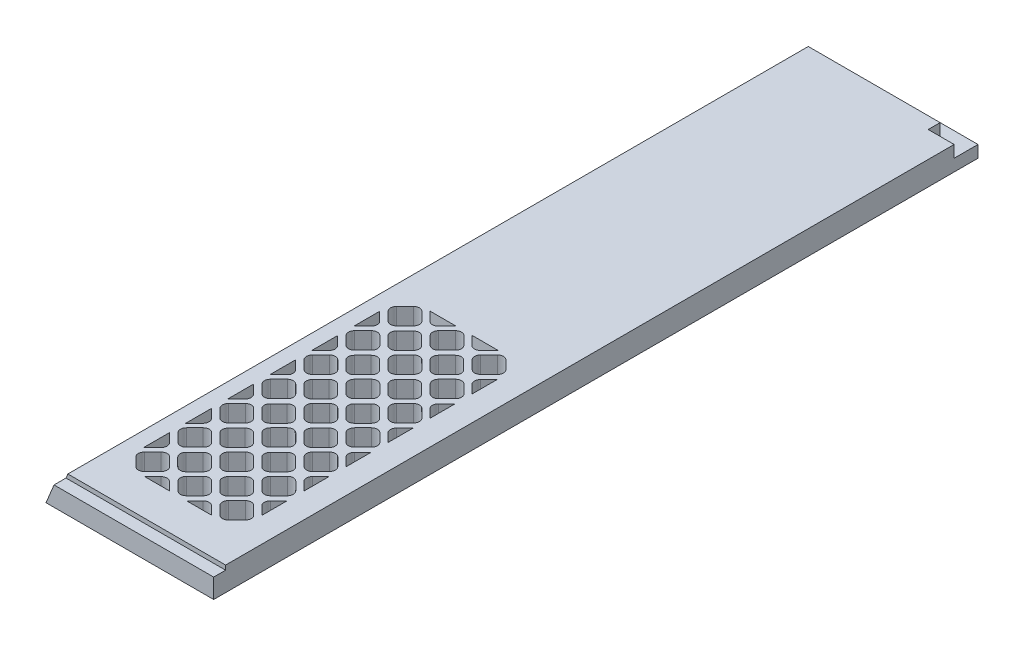
from build123d import *

# Parameters (mm, degrees)
BOSS_EXTRUDE1_DEPTH = 406.4
SKETCH2_W           = 89.154
SKETCH2_H           = 6.35
CUT_EXTRUDE1_DEPTH  = 2.3622
CUT_EXTRUDE2_DEPTH  = 13.7
CUT_EXTRUDE3_DEPTH  = 6.35


with BuildPart() as part:
    # Sketch1 → Boss-Extrude1 (new body)
    with BuildSketch(Plane.XY):
        Polygon((0, 0), (5.260512242, 12.7), (89.154, 12.7), (89.154, 0), align=None)
    extrude(amount=BOSS_EXTRUDE1_DEPTH)

    # Sketch2 → Cut-Extrude1 (cut)
    with BuildSketch(Plane.XZ.offset(-12.7)):
        with Locations((44.577, 403.225)):
            Rectangle(SKETCH2_W, SKETCH2_H)
    extrude(amount=CUT_EXTRUDE1_DEPTH, mode=Mode.SUBTRACT)

    # Sketch3 → Cut-Extrude2 (cut, through all)
    with BuildSketch(Plane.XZ):
        with BuildLine():
            ThreePointArc((28.960192091, 374.10106403), (29.890128061, 371.856), (28.960192091, 369.61093597))
            Line((28.960192091, 369.61093597), (24.47006403, 365.120807909))
            ThreePointArc((24.47006403, 365.120807909), (22.225, 364.190871939), (19.97993597, 365.120807909))
            Line((19.97993597, 365.120807909), (15.489807909, 369.61093597))
            ThreePointArc((15.489807909, 369.61093597), (14.559871939, 371.856), (15.489807909, 374.10106403))
            Line((15.489807909, 374.10106403), (19.97993597, 378.591192091))
            ThreePointArc((19.97993597, 378.591192091), (22.225, 379.521128061), (24.47006403, 378.591192091))
            Line((24.47006403, 378.591192091), (28.960192091, 374.10106403))
        make_face()
        with BuildLine():
            Line((37.841807909, 374.10106403), (42.33193597, 378.591192091))
            ThreePointArc((42.33193597, 378.591192091), (44.577, 379.521128061), (46.82206403, 378.591192091))
            Line((46.82206403, 378.591192091), (51.312192091, 374.10106403))
            ThreePointArc((51.312192091, 374.10106403), (52.242128061, 371.856), (51.312192091, 369.61093597))
            Line((51.312192091, 369.61093597), (46.82206403, 365.120807909))
            ThreePointArc((46.82206403, 365.120807909), (44.577, 364.190871939), (42.33193597, 365.120807909))
            Line((42.33193597, 365.120807909), (37.841807909, 369.61093597))
            ThreePointArc((37.841807909, 369.61093597), (36.911871939, 371.856), (37.841807909, 374.10106403))
        make_face()
        with BuildLine():
            Line((60.193807909, 374.10106403), (64.68393597, 378.591192091))
            ThreePointArc((64.68393597, 378.591192091), (66.929, 379.521128061), (69.17406403, 378.591192091))
            Line((69.17406403, 378.591192091), (73.664192091, 374.10106403))
            ThreePointArc((73.664192091, 374.10106403), (74.594128061, 371.856), (73.664192091, 369.61093597))
            Line((73.664192091, 369.61093597), (69.17406403, 365.120807909))
            ThreePointArc((69.17406403, 365.120807909), (66.929, 364.190871939), (64.68393597, 365.120807909))
            Line((64.68393597, 365.120807909), (60.193807909, 369.61093597))
            ThreePointArc((60.193807909, 369.61093597), (59.263871939, 371.856), (60.193807909, 374.10106403))
        make_face()
        with BuildLine():
            ThreePointArc((53.598045847, 367.603942271), (55.843109877, 368.533878241), (58.088173908, 367.603942271))
            Line((58.088173908, 367.603942271), (62.578301968, 363.113814211))
            ThreePointArc((62.578301968, 363.113814211), (63.508237938, 360.86875018), (62.578301968, 358.62368615))
            Line((62.578301968, 358.62368615), (58.088173908, 354.13355809))
            ThreePointArc((58.088173908, 354.13355809), (55.843109877, 353.20362212), (53.598045847, 354.13355809))
            Line((53.598045847, 354.13355809), (49.107917787, 358.62368615))
            ThreePointArc((49.107917787, 358.62368615), (48.177981817, 360.86875018), (49.107917787, 363.113814211))
            Line((49.107917787, 363.113814211), (53.598045847, 367.603942271))
        make_face()
        with BuildLine():
            ThreePointArc((31.246045847, 367.603942271), (33.491109877, 368.533878241), (35.736173908, 367.603942271))
            Line((35.736173908, 367.603942271), (40.226301968, 363.113814211))
            ThreePointArc((40.226301968, 363.113814211), (41.156237938, 360.86875018), (40.226301968, 358.62368615))
            Line((40.226301968, 358.62368615), (35.736173908, 354.13355809))
            ThreePointArc((35.736173908, 354.13355809), (33.491109877, 353.20362212), (31.246045847, 354.13355809))
            Line((31.246045847, 354.13355809), (26.755917787, 358.62368615))
            ThreePointArc((26.755917787, 358.62368615), (25.825981817, 360.86875018), (26.755917787, 363.113814211))
            Line((26.755917787, 363.113814211), (31.246045847, 367.603942271))
        make_face()
        with BuildLine():
            Line((15.489807909, 351.74906403), (19.97993597, 356.239192091))
            ThreePointArc((19.97993597, 356.239192091), (22.225, 357.169128061), (24.47006403, 356.239192091))
            Line((24.47006403, 356.239192091), (28.960192091, 351.74906403))
            ThreePointArc((28.960192091, 351.74906403), (29.890128061, 349.504), (28.960192091, 347.25893597))
            Line((28.960192091, 347.25893597), (24.47006403, 342.768807909))
            ThreePointArc((24.47006403, 342.768807909), (22.225, 341.838871939), (19.97993597, 342.768807909))
            Line((19.97993597, 342.768807909), (15.489807909, 347.25893597))
            ThreePointArc((15.489807909, 347.25893597), (14.559871939, 349.504), (15.489807909, 351.74906403))
        make_face()
        with BuildLine():
            Line((37.841807909, 351.74906403), (42.33193597, 356.239192091))
            ThreePointArc((42.33193597, 356.239192091), (44.577, 357.169128061), (46.82206403, 356.239192091))
            Line((46.82206403, 356.239192091), (51.312192091, 351.74906403))
            ThreePointArc((51.312192091, 351.74906403), (52.242128061, 349.504), (51.312192091, 347.25893597))
            Line((51.312192091, 347.25893597), (46.82206403, 342.768807909))
            ThreePointArc((46.82206403, 342.768807909), (44.577, 341.838871939), (42.33193597, 342.768807909))
            Line((42.33193597, 342.768807909), (37.841807909, 347.25893597))
            ThreePointArc((37.841807909, 347.25893597), (36.911871939, 349.504), (37.841807909, 351.74906403))
        make_face()
        with BuildLine():
            Line((60.193807909, 351.74906403), (64.68393597, 356.239192091))
            ThreePointArc((64.68393597, 356.239192091), (66.929, 357.169128061), (69.17406403, 356.239192091))
            Line((69.17406403, 356.239192091), (73.664192091, 351.74906403))
            ThreePointArc((73.664192091, 351.74906403), (74.594128061, 349.504), (73.664192091, 347.25893597))
            Line((73.664192091, 347.25893597), (69.17406403, 342.768807909))
            ThreePointArc((69.17406403, 342.768807909), (66.929, 341.838871939), (64.68393597, 342.768807909))
            Line((64.68393597, 342.768807909), (60.193807909, 347.25893597))
            ThreePointArc((60.193807909, 347.25893597), (59.263871939, 349.504), (60.193807909, 351.74906403))
        make_face()
        with BuildLine():
            ThreePointArc((53.598045847, 345.251942271), (55.843109877, 346.181878241), (58.088173908, 345.251942271))
            Line((58.088173908, 345.251942271), (62.578301968, 340.761814211))
            ThreePointArc((62.578301968, 340.761814211), (63.508237938, 338.51675018), (62.578301968, 336.27168615))
            Line((62.578301968, 336.27168615), (58.088173908, 331.78155809))
            ThreePointArc((58.088173908, 331.78155809), (55.843109877, 330.85162212), (53.598045847, 331.78155809))
            Line((53.598045847, 331.78155809), (49.107917787, 336.27168615))
            ThreePointArc((49.107917787, 336.27168615), (48.177981817, 338.51675018), (49.107917787, 340.761814211))
            Line((49.107917787, 340.761814211), (53.598045847, 345.251942271))
        make_face()
        with BuildLine():
            ThreePointArc((31.246045847, 345.251942271), (33.491109877, 346.181878241), (35.736173908, 345.251942271))
            Line((35.736173908, 345.251942271), (40.226301968, 340.761814211))
            ThreePointArc((40.226301968, 340.761814211), (41.156237938, 338.51675018), (40.226301968, 336.27168615))
            Line((40.226301968, 336.27168615), (35.736173908, 331.78155809))
            ThreePointArc((35.736173908, 331.78155809), (33.491109877, 330.85162212), (31.246045847, 331.78155809))
            Line((31.246045847, 331.78155809), (26.755917787, 336.27168615))
            ThreePointArc((26.755917787, 336.27168615), (25.825981817, 338.51675018), (26.755917787, 340.761814211))
            Line((26.755917787, 340.761814211), (31.246045847, 345.251942271))
        make_face()
        with BuildLine():
            Line((15.489807909, 329.39706403), (19.97993597, 333.887192091))
            ThreePointArc((19.97993597, 333.887192091), (22.225, 334.817128061), (24.47006403, 333.887192091))
            Line((24.47006403, 333.887192091), (28.960192091, 329.39706403))
            ThreePointArc((28.960192091, 329.39706403), (29.890128061, 327.152), (28.960192091, 324.90693597))
            Line((28.960192091, 324.90693597), (24.47006403, 320.416807909))
            ThreePointArc((24.47006403, 320.416807909), (22.225, 319.486871939), (19.97993597, 320.416807909))
            Line((19.97993597, 320.416807909), (15.489807909, 324.90693597))
            ThreePointArc((15.489807909, 324.90693597), (14.559871939, 327.152), (15.489807909, 329.39706403))
        make_face()
        with BuildLine():
            Line((37.841807909, 329.39706403), (42.33193597, 333.887192091))
            ThreePointArc((42.33193597, 333.887192091), (44.577, 334.817128061), (46.82206403, 333.887192091))
            Line((46.82206403, 333.887192091), (51.312192091, 329.39706403))
            ThreePointArc((51.312192091, 329.39706403), (52.242128061, 327.152), (51.312192091, 324.90693597))
            Line((51.312192091, 324.90693597), (46.82206403, 320.416807909))
            ThreePointArc((46.82206403, 320.416807909), (44.577, 319.486871939), (42.33193597, 320.416807909))
            Line((42.33193597, 320.416807909), (37.841807909, 324.90693597))
            ThreePointArc((37.841807909, 324.90693597), (36.911871939, 327.152), (37.841807909, 329.39706403))
        make_face()
        with BuildLine():
            Line((60.193807909, 329.39706403), (64.68393597, 333.887192091))
            ThreePointArc((64.68393597, 333.887192091), (66.929, 334.817128061), (69.17406403, 333.887192091))
            Line((69.17406403, 333.887192091), (73.664192091, 329.39706403))
            ThreePointArc((73.664192091, 329.39706403), (74.594128061, 327.152), (73.664192091, 324.90693597))
            Line((73.664192091, 324.90693597), (69.17406403, 320.416807909))
            ThreePointArc((69.17406403, 320.416807909), (66.929, 319.486871939), (64.68393597, 320.416807909))
            Line((64.68393597, 320.416807909), (60.193807909, 324.90693597))
            ThreePointArc((60.193807909, 324.90693597), (59.263871939, 327.152), (60.193807909, 329.39706403))
        make_face()
        with BuildLine():
            ThreePointArc((31.246045847, 322.899942271), (33.491109877, 323.829878241), (35.736173908, 322.899942271))
            Line((35.736173908, 322.899942271), (40.226301968, 318.409814211))
            ThreePointArc((40.226301968, 318.409814211), (41.156237938, 316.164750181), (40.226301968, 313.91968615))
            Line((40.226301968, 313.91968615), (35.736173908, 309.42955809))
            ThreePointArc((35.736173908, 309.42955809), (33.491109877, 308.49962212), (31.246045847, 309.42955809))
            Line((31.246045847, 309.42955809), (26.755917787, 313.91968615))
            ThreePointArc((26.755917787, 313.91968615), (25.825981817, 316.164750181), (26.755917787, 318.409814211))
            Line((26.755917787, 318.409814211), (31.246045847, 322.899942271))
        make_face()
        with BuildLine():
            ThreePointArc((53.598045847, 322.899942271), (55.843109877, 323.829878241), (58.088173908, 322.899942271))
            Line((58.088173908, 322.899942271), (62.578301968, 318.409814211))
            ThreePointArc((62.578301968, 318.409814211), (63.508237938, 316.164750181), (62.578301968, 313.91968615))
            Line((62.578301968, 313.91968615), (58.088173908, 309.42955809))
            ThreePointArc((58.088173908, 309.42955809), (55.843109877, 308.49962212), (53.598045847, 309.42955809))
            Line((53.598045847, 309.42955809), (49.107917787, 313.91968615))
            ThreePointArc((49.107917787, 313.91968615), (48.177981817, 316.164750181), (49.107917787, 318.409814211))
            Line((49.107917787, 318.409814211), (53.598045847, 322.899942271))
        make_face()
        with BuildLine():
            Line((15.489807909, 307.04506403), (19.97993597, 311.535192091))
            ThreePointArc((19.97993597, 311.535192091), (22.225, 312.465128061), (24.47006403, 311.535192091))
            Line((24.47006403, 311.535192091), (28.960192091, 307.04506403))
            ThreePointArc((28.960192091, 307.04506403), (29.890128061, 304.8), (28.960192091, 302.55493597))
            Line((28.960192091, 302.55493597), (24.47006403, 298.064807909))
            ThreePointArc((24.47006403, 298.064807909), (22.225, 297.134871939), (19.97993597, 298.064807909))
            Line((19.97993597, 298.064807909), (15.489807909, 302.55493597))
            ThreePointArc((15.489807909, 302.55493597), (14.559871939, 304.8), (15.489807909, 307.04506403))
        make_face()
        with BuildLine():
            Line((37.841807909, 307.04506403), (42.33193597, 311.535192091))
            ThreePointArc((42.33193597, 311.535192091), (44.577, 312.465128061), (46.82206403, 311.535192091))
            Line((46.82206403, 311.535192091), (51.312192091, 307.04506403))
            ThreePointArc((51.312192091, 307.04506403), (52.242128061, 304.8), (51.312192091, 302.55493597))
            Line((51.312192091, 302.55493597), (46.82206403, 298.064807909))
            ThreePointArc((46.82206403, 298.064807909), (44.577, 297.134871939), (42.33193597, 298.064807909))
            Line((42.33193597, 298.064807909), (37.841807909, 302.55493597))
            ThreePointArc((37.841807909, 302.55493597), (36.911871939, 304.8), (37.841807909, 307.04506403))
        make_face()
        with BuildLine():
            Line((60.193807909, 307.04506403), (64.68393597, 311.535192091))
            ThreePointArc((64.68393597, 311.535192091), (66.929, 312.465128061), (69.17406403, 311.535192091))
            Line((69.17406403, 311.535192091), (73.664192091, 307.04506403))
            ThreePointArc((73.664192091, 307.04506403), (74.594128061, 304.8), (73.664192091, 302.55493597))
            Line((73.664192091, 302.55493597), (69.17406403, 298.064807909))
            ThreePointArc((69.17406403, 298.064807909), (66.929, 297.134871939), (64.68393597, 298.064807909))
            Line((64.68393597, 298.064807909), (60.193807909, 302.55493597))
            ThreePointArc((60.193807909, 302.55493597), (59.263871939, 304.8), (60.193807909, 307.04506403))
        make_face()
        with BuildLine():
            ThreePointArc((53.598045847, 300.547942271), (55.843109877, 301.477878241), (58.088173908, 300.547942271))
            Line((58.088173908, 300.547942271), (62.578301968, 296.057814211))
            ThreePointArc((62.578301968, 296.057814211), (63.508237938, 293.812750181), (62.578301968, 291.56768615))
            Line((62.578301968, 291.56768615), (58.088173908, 287.07755809))
            ThreePointArc((58.088173908, 287.07755809), (55.843109877, 286.14762212), (53.598045847, 287.07755809))
            Line((53.598045847, 287.07755809), (49.107917787, 291.56768615))
            ThreePointArc((49.107917787, 291.56768615), (48.177981817, 293.812750181), (49.107917787, 296.057814211))
            Line((49.107917787, 296.057814211), (53.598045847, 300.547942271))
        make_face()
        with BuildLine():
            ThreePointArc((31.246045847, 300.547942271), (33.491109877, 301.477878241), (35.736173908, 300.547942271))
            Line((35.736173908, 300.547942271), (40.226301968, 296.057814211))
            ThreePointArc((40.226301968, 296.057814211), (41.156237938, 293.812750181), (40.226301968, 291.56768615))
            Line((40.226301968, 291.56768615), (35.736173908, 287.07755809))
            ThreePointArc((35.736173908, 287.07755809), (33.491109877, 286.14762212), (31.246045847, 287.07755809))
            Line((31.246045847, 287.07755809), (26.755917787, 291.56768615))
            ThreePointArc((26.755917787, 291.56768615), (25.825981817, 293.812750181), (26.755917787, 296.057814211))
            Line((26.755917787, 296.057814211), (31.246045847, 300.547942271))
        make_face()
        with BuildLine():
            Line((15.489807909, 284.69306403), (19.97993597, 289.183192091))
            ThreePointArc((19.97993597, 289.183192091), (22.225, 290.113128061), (24.47006403, 289.183192091))
            Line((24.47006403, 289.183192091), (28.960192091, 284.69306403))
            ThreePointArc((28.960192091, 284.69306403), (29.890128061, 282.448), (28.960192091, 280.20293597))
            Line((28.960192091, 280.20293597), (24.47006403, 275.712807909))
            ThreePointArc((24.47006403, 275.712807909), (22.225, 274.782871939), (19.97993597, 275.712807909))
            Line((19.97993597, 275.712807909), (15.489807909, 280.20293597))
            ThreePointArc((15.489807909, 280.20293597), (14.559871939, 282.448), (15.489807909, 284.69306403))
        make_face()
        with BuildLine():
            Line((15.489807909, 262.34106403), (19.97993597, 266.831192091))
            ThreePointArc((19.97993597, 266.831192091), (22.225, 267.761128061), (24.47006403, 266.831192091))
            Line((24.47006403, 266.831192091), (28.960192091, 262.34106403))
            ThreePointArc((28.960192091, 262.34106403), (29.890128061, 260.096), (28.960192091, 257.85093597))
            Line((28.960192091, 257.85093597), (24.47006403, 253.360807909))
            ThreePointArc((24.47006403, 253.360807909), (22.225, 252.430871939), (19.97993597, 253.360807909))
            Line((19.97993597, 253.360807909), (15.489807909, 257.85093597))
            ThreePointArc((15.489807909, 257.85093597), (14.559871939, 260.096), (15.489807909, 262.34106403))
        make_face()
        with BuildLine():
            Line((15.489807909, 239.98906403), (19.97993597, 244.479192091))
            ThreePointArc((19.97993597, 244.479192091), (22.225, 245.409128061), (24.47006403, 244.479192091))
            Line((24.47006403, 244.479192091), (28.960192091, 239.98906403))
            ThreePointArc((28.960192091, 239.98906403), (29.890128061, 237.744), (28.960192091, 235.49893597))
            Line((28.960192091, 235.49893597), (24.47006403, 231.008807909))
            ThreePointArc((24.47006403, 231.008807909), (22.225, 230.078871939), (19.97993597, 231.008807909))
            Line((19.97993597, 231.008807909), (15.489807909, 235.49893597))
            ThreePointArc((15.489807909, 235.49893597), (14.559871939, 237.744), (15.489807909, 239.98906403))
        make_face()
        with BuildLine():
            ThreePointArc((31.246045847, 255.843942272), (33.491109877, 256.773878241), (35.736173908, 255.843942272))
            Line((35.736173908, 255.843942272), (40.226301968, 251.353814211))
            ThreePointArc((40.226301968, 251.353814211), (41.156237938, 249.108750181), (40.226301968, 246.863686151))
            Line((40.226301968, 246.863686151), (35.736173908, 242.37355809))
            ThreePointArc((35.736173908, 242.37355809), (33.491109877, 241.44362212), (31.246045847, 242.37355809))
            Line((31.246045847, 242.37355809), (26.755917787, 246.863686151))
            ThreePointArc((26.755917787, 246.863686151), (25.825981817, 249.108750181), (26.755917787, 251.353814211))
            Line((26.755917787, 251.353814211), (31.246045847, 255.843942272))
        make_face()
        with BuildLine():
            ThreePointArc((31.246045847, 278.195942272), (33.491109877, 279.125878241), (35.736173908, 278.195942272))
            Line((35.736173908, 278.195942272), (40.226301968, 273.705814211))
            ThreePointArc((40.226301968, 273.705814211), (41.156237938, 271.460750181), (40.226301968, 269.215686151))
            Line((40.226301968, 269.215686151), (35.736173908, 264.72555809))
            ThreePointArc((35.736173908, 264.72555809), (33.491109877, 263.79562212), (31.246045847, 264.72555809))
            Line((31.246045847, 264.72555809), (26.755917787, 269.215686151))
            ThreePointArc((26.755917787, 269.215686151), (25.825981817, 271.460750181), (26.755917787, 273.705814211))
            Line((26.755917787, 273.705814211), (31.246045847, 278.195942272))
        make_face()
        with BuildLine():
            Line((37.841807909, 284.69306403), (42.33193597, 289.183192091))
            ThreePointArc((42.33193597, 289.183192091), (44.577, 290.113128061), (46.82206403, 289.183192091))
            Line((46.82206403, 289.183192091), (51.312192091, 284.69306403))
            ThreePointArc((51.312192091, 284.69306403), (52.242128061, 282.448), (51.312192091, 280.20293597))
            Line((51.312192091, 280.20293597), (46.82206403, 275.712807909))
            ThreePointArc((46.82206403, 275.712807909), (44.577, 274.782871939), (42.33193597, 275.712807909))
            Line((42.33193597, 275.712807909), (37.841807909, 280.20293597))
            ThreePointArc((37.841807909, 280.20293597), (36.911871939, 282.448), (37.841807909, 284.69306403))
        make_face()
        with BuildLine():
            Line((37.841807909, 262.34106403), (42.33193597, 266.831192091))
            ThreePointArc((42.33193597, 266.831192091), (44.577, 267.761128061), (46.82206403, 266.831192091))
            Line((46.82206403, 266.831192091), (51.312192091, 262.34106403))
            ThreePointArc((51.312192091, 262.34106403), (52.242128061, 260.096), (51.312192091, 257.85093597))
            Line((51.312192091, 257.85093597), (46.82206403, 253.360807909))
            ThreePointArc((46.82206403, 253.360807909), (44.577, 252.430871939), (42.33193597, 253.360807909))
            Line((42.33193597, 253.360807909), (37.841807909, 257.85093597))
            ThreePointArc((37.841807909, 257.85093597), (36.911871939, 260.096), (37.841807909, 262.34106403))
        make_face()
        with BuildLine():
            Line((37.841807909, 239.98906403), (42.33193597, 244.479192091))
            ThreePointArc((42.33193597, 244.479192091), (44.577, 245.409128061), (46.82206403, 244.479192091))
            Line((46.82206403, 244.479192091), (51.312192091, 239.98906403))
            ThreePointArc((51.312192091, 239.98906403), (52.242128061, 237.744), (51.312192091, 235.49893597))
            Line((51.312192091, 235.49893597), (46.82206403, 231.008807909))
            ThreePointArc((46.82206403, 231.008807909), (44.577, 230.078871939), (42.33193597, 231.008807909))
            Line((42.33193597, 231.008807909), (37.841807909, 235.49893597))
            ThreePointArc((37.841807909, 235.49893597), (36.911871939, 237.744), (37.841807909, 239.98906403))
        make_face()
        with BuildLine():
            ThreePointArc((53.598045847, 278.195942272), (55.843109877, 279.125878241), (58.088173908, 278.195942272))
            Line((58.088173908, 278.195942272), (62.578301968, 273.705814211))
            ThreePointArc((62.578301968, 273.705814211), (63.508237938, 271.460750181), (62.578301968, 269.215686151))
            Line((62.578301968, 269.215686151), (58.088173908, 264.72555809))
            ThreePointArc((58.088173908, 264.72555809), (55.843109877, 263.79562212), (53.598045847, 264.72555809))
            Line((53.598045847, 264.72555809), (49.107917787, 269.215686151))
            ThreePointArc((49.107917787, 269.215686151), (48.177981817, 271.460750181), (49.107917787, 273.705814211))
            Line((49.107917787, 273.705814211), (53.598045847, 278.195942272))
        make_face()
        with BuildLine():
            Line((60.193807909, 284.69306403), (64.68393597, 289.183192091))
            ThreePointArc((64.68393597, 289.183192091), (66.929, 290.113128061), (69.17406403, 289.183192091))
            Line((69.17406403, 289.183192091), (73.664192091, 284.69306403))
            ThreePointArc((73.664192091, 284.69306403), (74.594128061, 282.448), (73.664192091, 280.20293597))
            Line((73.664192091, 280.20293597), (69.17406403, 275.712807909))
            ThreePointArc((69.17406403, 275.712807909), (66.929, 274.782871939), (64.68393597, 275.712807909))
            Line((64.68393597, 275.712807909), (60.193807909, 280.20293597))
            ThreePointArc((60.193807909, 280.20293597), (59.263871939, 282.448), (60.193807909, 284.69306403))
        make_face()
        with BuildLine():
            Line((60.193807909, 262.34106403), (64.68393597, 266.831192091))
            ThreePointArc((64.68393597, 266.831192091), (66.929, 267.761128061), (69.17406403, 266.831192091))
            Line((69.17406403, 266.831192091), (73.664192091, 262.34106403))
            ThreePointArc((73.664192091, 262.34106403), (74.594128061, 260.096), (73.664192091, 257.85093597))
            Line((73.664192091, 257.85093597), (69.17406403, 253.360807909))
            ThreePointArc((69.17406403, 253.360807909), (66.929, 252.430871939), (64.68393597, 253.360807909))
            Line((64.68393597, 253.360807909), (60.193807909, 257.85093597))
            ThreePointArc((60.193807909, 257.85093597), (59.263871939, 260.096), (60.193807909, 262.34106403))
        make_face()
        with BuildLine():
            ThreePointArc((53.598045847, 255.843942272), (55.843109877, 256.773878241), (58.088173908, 255.843942272))
            Line((58.088173908, 255.843942272), (62.578301968, 251.353814211))
            ThreePointArc((62.578301968, 251.353814211), (63.508237938, 249.108750181), (62.578301968, 246.863686151))
            Line((62.578301968, 246.863686151), (58.088173908, 242.37355809))
            ThreePointArc((58.088173908, 242.37355809), (55.843109877, 241.44362212), (53.598045847, 242.37355809))
            Line((53.598045847, 242.37355809), (49.107917787, 246.863686151))
            ThreePointArc((49.107917787, 246.863686151), (48.177981817, 249.108750181), (49.107917787, 251.353814211))
            Line((49.107917787, 251.353814211), (53.598045847, 255.843942272))
        make_face()
        with BuildLine():
            Line((60.193807909, 239.98906403), (64.68393597, 244.479192091))
            ThreePointArc((64.68393597, 244.479192091), (66.929, 245.409128061), (69.17406403, 244.479192091))
            Line((69.17406403, 244.479192091), (73.664192091, 239.98906403))
            ThreePointArc((73.664192091, 239.98906403), (74.594128061, 237.744), (73.664192091, 235.49893597))
            Line((73.664192091, 235.49893597), (69.17406403, 231.008807909))
            ThreePointArc((69.17406403, 231.008807909), (66.929, 230.078871939), (64.68393597, 231.008807909))
            Line((64.68393597, 231.008807909), (60.193807909, 235.49893597))
            ThreePointArc((60.193807909, 235.49893597), (59.263871939, 237.744), (60.193807909, 239.98906403))
        make_face()
        with BuildLine():
            Line((13.244743879, 367.735205334), (13.244743879, 354.002295027))
            ThreePointArc((13.244743879, 354.002295027), (13.315448739, 354.066875126), (13.384173908, 354.13355809))
            Line((13.384173908, 354.13355809), (17.874301968, 358.62368615))
            ThreePointArc((17.874301968, 358.62368615), (18.804237938, 360.86875018), (17.874301968, 363.113814211))
            Line((17.874301968, 363.113814211), (13.384173908, 367.603942271))
            ThreePointArc((13.384173908, 367.603942271), (13.315448739, 367.670625234), (13.244743879, 367.735205334))
        make_face()
        with BuildLine():
            Line((13.244743879, 345.383205334), (13.244743879, 331.650295027))
            ThreePointArc((13.244743879, 331.650295027), (13.315448739, 331.714875127), (13.384173908, 331.78155809))
            Line((13.384173908, 331.78155809), (17.874301968, 336.27168615))
            ThreePointArc((17.874301968, 336.27168615), (18.804237938, 338.51675018), (17.874301968, 340.761814211))
            Line((17.874301968, 340.761814211), (13.384173908, 345.251942271))
            ThreePointArc((13.384173908, 345.251942271), (13.315448739, 345.318625234), (13.244743879, 345.383205334))
        make_face()
        with BuildLine():
            Line((13.244743879, 323.031205334), (13.244743879, 309.298295027))
            ThreePointArc((13.244743879, 309.298295027), (13.315448739, 309.362875127), (13.384173908, 309.42955809))
            Line((13.384173908, 309.42955809), (17.874301968, 313.91968615))
            ThreePointArc((17.874301968, 313.91968615), (18.804237938, 316.16475018), (17.874301968, 318.409814211))
            Line((17.874301968, 318.409814211), (13.384173908, 322.899942271))
            ThreePointArc((13.384173908, 322.899942271), (13.315448739, 322.966625234), (13.244743879, 323.031205334))
        make_face()
        with BuildLine():
            Line((40.086871939, 380.836256121), (26.895347816, 380.836256121))
            Line((26.895347816, 380.836256121), (31.246045847, 376.485558089))
            ThreePointArc((31.246045847, 376.485558089), (33.491109877, 375.55562212), (35.736173908, 376.485558089))
            Line((35.736173908, 376.485558089), (40.086871939, 380.836256121))
        make_face()
        with BuildLine():
            Line((62.438871939, 380.836256121), (49.247347815, 380.836256121))
            Line((49.247347815, 380.836256121), (53.598045847, 376.485558089))
            ThreePointArc((53.598045847, 376.485558089), (55.843109877, 375.55562212), (58.088173908, 376.485558089))
            Line((58.088173908, 376.485558089), (62.438871939, 380.836256121))
        make_face()
        with BuildLine():
            Line((71.459917787, 358.62368615), (75.909256121, 354.174347816))
            Line((75.909256121, 354.174347816), (75.909256121, 367.563152545))
            Line((75.909256121, 367.563152545), (71.459917787, 363.113814211))
            ThreePointArc((71.459917787, 363.113814211), (70.529981817, 360.86875018), (71.459917787, 358.62368615))
        make_face()
        with BuildLine():
            Line((71.459917787, 336.27168615), (75.909256121, 331.822347816))
            Line((75.909256121, 331.822347816), (75.909256121, 345.211152545))
            Line((75.909256121, 345.211152545), (71.459917787, 340.761814211))
            ThreePointArc((71.459917787, 340.761814211), (70.529981817, 338.51675018), (71.459917787, 336.27168615))
        make_face()
        with BuildLine():
            Line((71.459917786, 313.91968615), (75.909256121, 309.470347816))
            Line((75.909256121, 309.470347816), (75.909256121, 322.859152545))
            Line((75.909256121, 322.859152545), (71.459917786, 318.409814211))
            ThreePointArc((71.459917786, 318.409814211), (70.529981817, 316.164750181), (71.459917786, 313.91968615))
        make_face()
        with BuildLine():
            Line((71.459917786, 291.56768615), (75.909256121, 287.118347816))
            Line((75.909256121, 287.118347816), (75.909256121, 300.507152545))
            Line((75.909256121, 300.507152545), (71.459917786, 296.057814211))
            ThreePointArc((71.459917786, 296.057814211), (70.529981817, 293.812750181), (71.459917786, 291.56768615))
        make_face()
        with BuildLine():
            Line((13.244743879, 300.679205334), (13.244743879, 286.946295027))
            ThreePointArc((13.244743879, 286.946295027), (13.315448739, 287.010875127), (13.384173908, 287.07755809))
            Line((13.384173908, 287.07755809), (17.874301968, 291.56768615))
            ThreePointArc((17.874301968, 291.56768615), (18.804237938, 293.812750181), (17.874301968, 296.057814211))
            Line((17.874301968, 296.057814211), (13.384173908, 300.547942271))
            ThreePointArc((13.384173908, 300.547942271), (13.315448739, 300.614625234), (13.244743879, 300.679205334))
        make_face()
        with BuildLine():
            Line((71.459917786, 269.21568615), (75.909256121, 264.766347816))
            Line((75.909256121, 264.766347816), (75.909256121, 278.155152546))
            Line((75.909256121, 278.155152546), (71.459917786, 273.705814211))
            ThreePointArc((71.459917786, 273.705814211), (70.529981817, 271.460750181), (71.459917786, 269.21568615))
        make_face()
        with BuildLine():
            Line((71.459917787, 246.86368615), (75.909256121, 242.414347816))
            Line((75.909256121, 242.414347816), (75.909256121, 255.803152545))
            Line((75.909256121, 255.803152545), (71.459917787, 251.353814211))
            ThreePointArc((71.459917787, 251.353814211), (70.529981817, 249.108750181), (71.459917787, 246.86368615))
        make_face()
        with BuildLine():
            ThreePointArc((49.107917787, 229.001814211), (48.997338588, 228.885498635), (48.89277831, 228.763743879))
            Line((48.89277831, 228.763743879), (62.793441445, 228.763743879))
            ThreePointArc((62.793441445, 228.763743879), (62.688881166, 228.885498635), (62.578301968, 229.001814211))
            Line((62.578301968, 229.001814211), (58.088173908, 233.491942271))
            ThreePointArc((58.088173908, 233.491942271), (55.843109877, 234.421878241), (53.598045847, 233.491942271))
            Line((53.598045847, 233.491942271), (49.107917787, 229.001814211))
        make_face()
        with BuildLine():
            ThreePointArc((26.755917787, 229.001814211), (26.645338589, 228.885498635), (26.54077831, 228.763743879))
            Line((26.54077831, 228.763743879), (40.441441445, 228.763743879))
            ThreePointArc((40.441441445, 228.763743879), (40.336881166, 228.885498635), (40.226301968, 229.001814211))
            Line((40.226301968, 229.001814211), (35.736173908, 233.491942271))
            ThreePointArc((35.736173908, 233.491942271), (33.491109878, 234.421878241), (31.246045847, 233.491942271))
            Line((31.246045847, 233.491942271), (26.755917787, 229.001814211))
        make_face()
        with BuildLine():
            Line((13.244743879, 255.975205334), (13.244743879, 242.242295027))
            ThreePointArc((13.244743879, 242.242295027), (13.315448739, 242.306875127), (13.384173908, 242.37355809))
            Line((13.384173908, 242.37355809), (17.874301968, 246.863686151))
            ThreePointArc((17.874301968, 246.863686151), (18.804237938, 249.108750181), (17.874301968, 251.353814211))
            Line((17.874301968, 251.353814211), (13.384173908, 255.843942271))
            ThreePointArc((13.384173908, 255.843942271), (13.315448739, 255.910625234), (13.244743879, 255.975205334))
        make_face()
        with BuildLine():
            Line((13.244743879, 278.327205334), (13.244743879, 264.594295027))
            ThreePointArc((13.244743879, 264.594295027), (13.315448739, 264.658875127), (13.384173908, 264.72555809))
            Line((13.384173908, 264.72555809), (17.874301968, 269.215686151))
            ThreePointArc((17.874301968, 269.215686151), (18.804237938, 271.460750181), (17.874301968, 273.705814211))
            Line((17.874301968, 273.705814211), (13.384173908, 278.195942271))
            ThreePointArc((13.384173908, 278.195942271), (13.315448739, 278.262625234), (13.244743879, 278.327205334))
        make_face()
    extrude(amount=-CUT_EXTRUDE2_DEPTH, mode=Mode.SUBTRACT)

    # Sketch4 → Cut-Extrude3 (cut)
    with BuildSketch(Plane(origin=(0, 12.7, 0), x_dir=(1, 0, 0), z_dir=(0, 1, 0))):
        Polygon((89.154, 0), (-9.102448513, 0), (-9.102448513, -6.35), (75.368911977, -6.35), (75.368911977, -12.7), (89.154, -12.7), (89.154, -6.35), align=None)
    extrude(amount=-CUT_EXTRUDE3_DEPTH, mode=Mode.SUBTRACT)


solid = part.part
